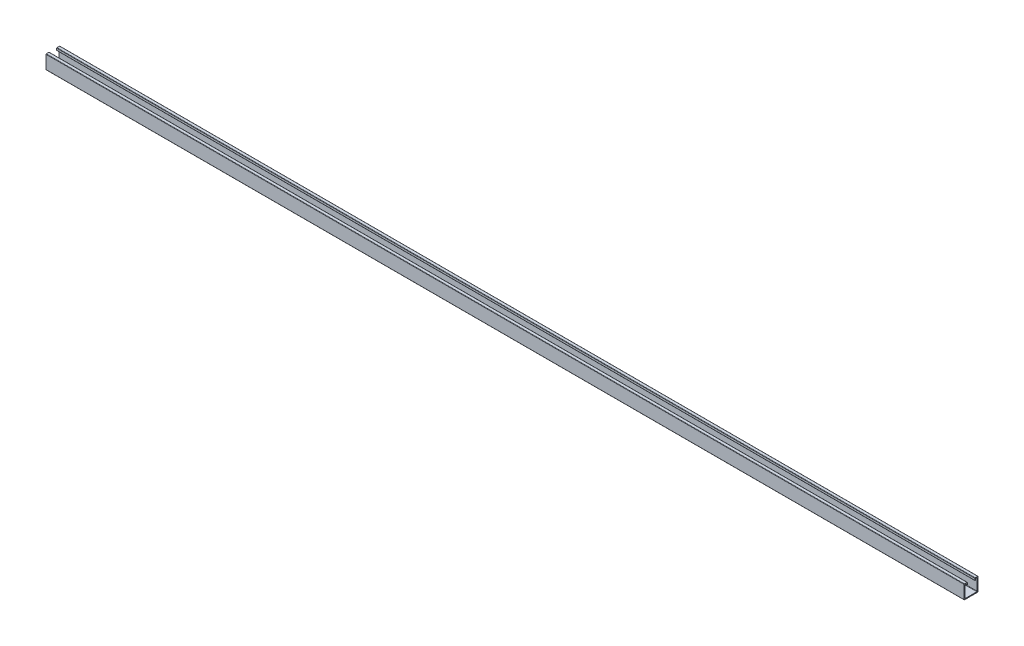
from build123d import *

# Parameters (mm, degrees)
BOSS_EXTRUDE1_DEPTH = 2717.8


with BuildPart() as part:
    # Sketch1 → Boss-Extrude1 (new body)
    with BuildSketch(Plane(origin=(0, 0, 0), x_dir=(0, 0, -1), z_dir=(1, 0, 0))):
        with BuildLine():
            Line((-18, -17), (-18, 17))
            ThreePointArc((-18, 17), (-17.707106781, 17.707106781), (-17, 18))
            Line((-17, 18), (-14.5, 18))
            ThreePointArc((-14.5, 18), (-13.792893219, 17.707106781), (-13.5, 17))
            Line((-13.5, 17), (-13.5, 14.4))
            ThreePointArc((-13.5, 14.4), (-13.207106781, 13.692893219), (-12.5, 13.4))
            Line((-12.5, 13.4), (-12, 13.4))
            ThreePointArc((-12, 13.4), (-11.292893219, 13.692893219), (-11, 14.4))
            Line((-11, 14.4), (-11, 19.5))
            ThreePointArc((-11, 19.5), (-11.292893219, 20.207106781), (-12, 20.5))
            Line((-12, 20.5), (-19.5, 20.5))
            ThreePointArc((-19.5, 20.5), (-20.207106781, 20.207106781), (-20.5, 19.5))
            Line((-20.5, 19.5), (-20.5, -19.5))
            ThreePointArc((-20.5, -19.5), (-20.207106781, -20.207106781), (-19.5, -20.5))
            Line((-19.5, -20.5), (19.5, -20.5))
            ThreePointArc((19.5, -20.5), (20.207106781, -20.207106781), (20.5, -19.5))
            Line((20.5, -19.5), (20.5, 19.5))
            ThreePointArc((20.5, 19.5), (20.207106781, 20.207106781), (19.5, 20.5))
            Line((19.5, 20.5), (12, 20.5))
            ThreePointArc((12, 20.5), (11.292893219, 20.207106781), (11, 19.5))
            Line((11, 19.5), (11, 14.4))
            ThreePointArc((11, 14.4), (11.292893219, 13.692893219), (12, 13.4))
            Line((12, 13.4), (12.5, 13.4))
            ThreePointArc((12.5, 13.4), (13.207106781, 13.692893219), (13.5, 14.4))
            Line((13.5, 14.4), (13.5, 17))
            ThreePointArc((13.5, 17), (13.792893219, 17.707106781), (14.5, 18))
            Line((14.5, 18), (17, 18))
            ThreePointArc((17, 18), (17.707106781, 17.707106781), (18, 17))
            Line((18, 17), (18, -17))
            ThreePointArc((18, -17), (17.707106781, -17.707106781), (17, -18))
            Line((17, -18), (-17, -18))
            ThreePointArc((-17, -18), (-17.707106781, -17.707106781), (-18, -17))
        make_face()
    extrude(amount=BOSS_EXTRUDE1_DEPTH)


solid = part.part
